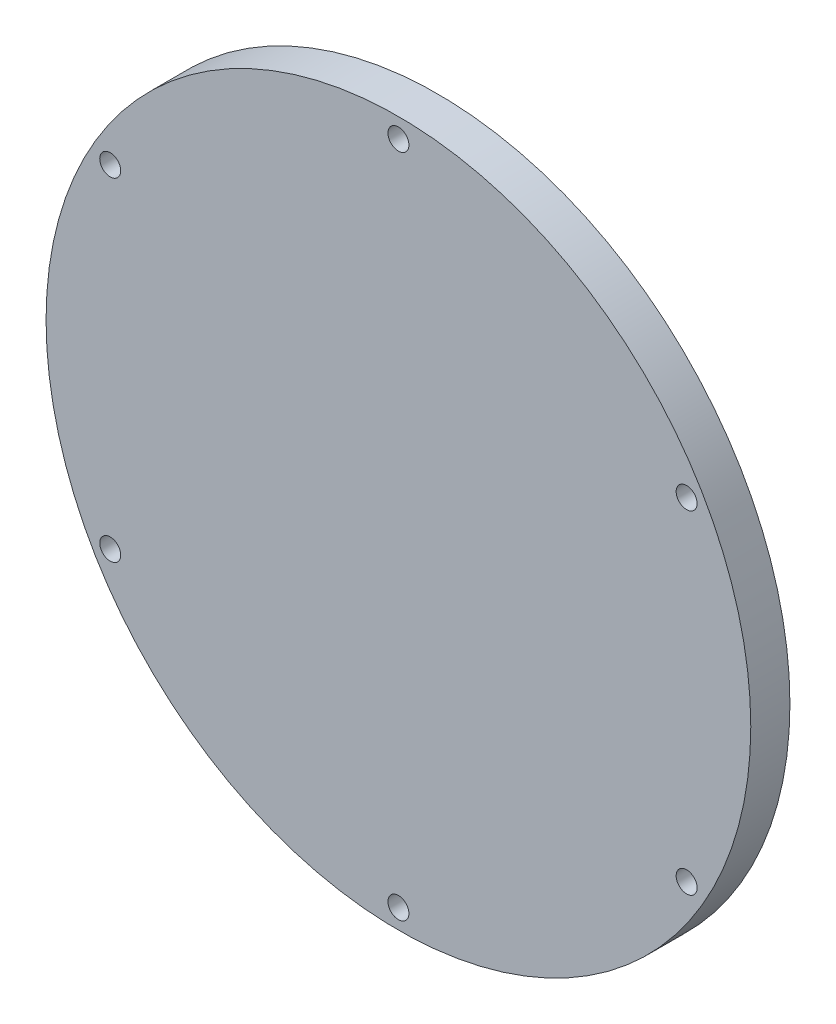
from build123d import *

# Parameters (mm, degrees)
SKETCH2_R           = 57.15
BOSS_EXTRUDE1_DEPTH = 6.35
SKETCH6_R           = 1.7
CUT_EXTRUDE4_DEPTH  = 7.35
CIRPATTERN3_COUNT   = 6


with BuildPart() as part:
    # Sketch2 → Boss-Extrude1 (new body)
    with BuildSketch(Plane.XY):
        Circle(SKETCH2_R)
    extrude(amount=BOSS_EXTRUDE1_DEPTH)

    # Sketch6 → Cut-Extrude4 (cut, through all)
    with BuildSketch(Plane.XY.offset(6.35)):
        with Locations((0, 53.975)):
            Circle(SKETCH6_R)
    cut_extrude4 = extrude(amount=-CUT_EXTRUDE4_DEPTH, mode=Mode.SUBTRACT)

    # CirPattern3: Cut-Extrude4 ×6 about axis
    cirpattern3_axis = Axis((0, 0, 0), (0, 0, 1))
    for i in range(1, CIRPATTERN3_COUNT):
        add(cut_extrude4.rotate(cirpattern3_axis, i * 360 / CIRPATTERN3_COUNT), mode=Mode.SUBTRACT)


solid = part.part
